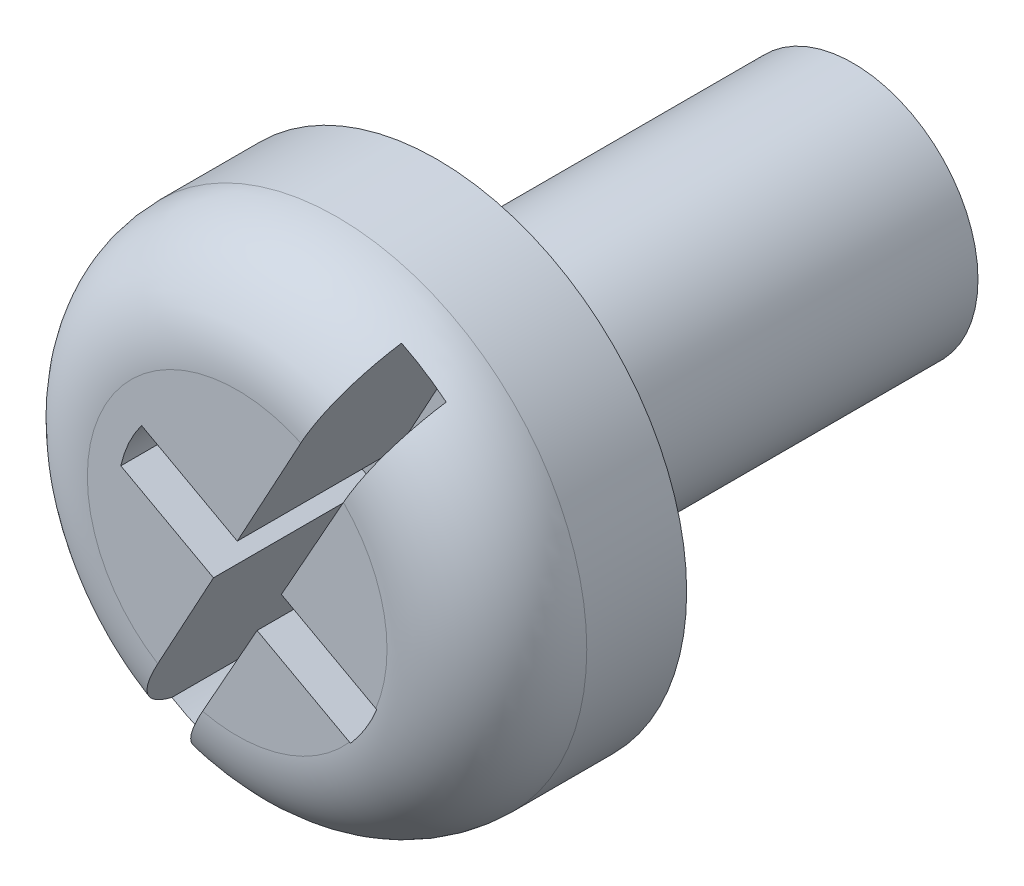
from build123d import *

# Parameters (mm, degrees)
SZKIC1_R                    = 3
DODANIE_WYCI_GNI_CIE2_DEPTH = 2.4
SZKIC2_R                    = 1.5
DODANIE_WYCI_GNI_CIE3_DEPTH = 5
ZAOKR_GLENIE2_R             = 1.2
WYTNIJ_WYCI_GNI_CIE1_DEPTH  = 1.94


with BuildPart() as part:
    # Szkic1 → Dodanie-wyciągnięcie2 (new body)
    with BuildSketch(Plane.XY):
        with Locations((-1.860516246, 2.732142857)):
            Circle(SZKIC1_R)
    extrude(amount=DODANIE_WYCI_GNI_CIE2_DEPTH)

    # Szkic2 → Dodanie-wyciągnięcie3 (add)
    with BuildSketch(Plane(origin=(0, 0, 0), x_dir=(-1, 0, 0), z_dir=(0, 0, -1))):
        with Locations((1.860516246, 2.732142857)):
            Circle(SZKIC2_R)
    extrude(amount=DODANIE_WYCI_GNI_CIE3_DEPTH)

    # Zaokrąglenie2
    zaokr_glenie2_edges = [part.edges().sort_by_distance(p)[0] for p in [
        (-4.860516246, 2.732142857, 2.4),
    ]]
    fillet(zaokr_glenie2_edges, radius=ZAOKR_GLENIE2_R)

    # Szkic3 → Wytnij-wyciągnięcie1 (cut)
    with BuildSketch(Plane.XY.offset(2.4)):
        with BuildLine():
            Line((-1.859548318, 2.959091853), (-0.575649693, 5.316481314))
            ThreePointArc((-0.575649693, 5.316481314), (-0.297886623, 5.158637444), (-0.039271083, 4.97106076))
            Line((-0.039271083, 4.97106076), (-1.329373025, 2.669425378))
            Line((-1.329373025, 2.669425378), (-0.183967515, 2.043621837))
            ThreePointArc((-0.183967515, 2.043621837), (-0.320475658, 1.776553075), (-0.499159616, 1.535654258))
            Line((-0.499159616, 1.535654258), (-1.621312108, 2.148584891))
            Line((-1.621312108, 2.148584891), (-2.819933608, 0.01015725))
            ThreePointArc((-2.819933608, 0.01015725), (-3.083174674, 0.117799023), (-3.33454353, 0.250826496))
            Line((-3.33454353, 0.250826496), (-2.145142944, 2.434706401))
            Line((-2.145142944, 2.434706401), (-3.258687897, 3.042935511))
            ThreePointArc((-3.258687897, 3.042935511), (-3.162842423, 3.328316127), (-3.009463836, 3.587359481))
            Line((-3.009463836, 3.587359481), (-1.859548318, 2.959091853))
        make_face()
    extrude(amount=-WYTNIJ_WYCI_GNI_CIE1_DEPTH, mode=Mode.SUBTRACT)


solid = part.part
